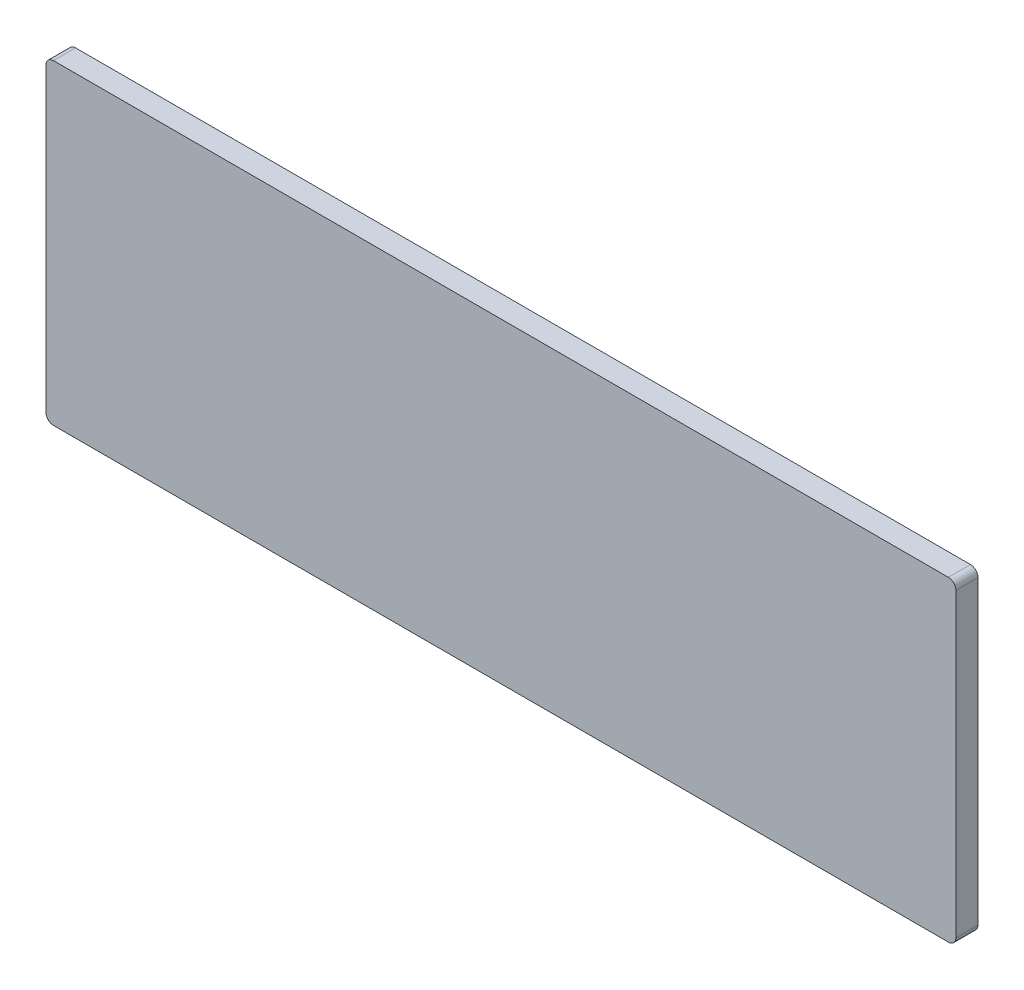
from build123d import *

# Parameters (mm, degrees)
SKETCH1_W           = 1828.8
SKETCH1_H           = 635
BOSS_EXTRUDE1_DEPTH = 44.45
FILLET1_R           = 15


with BuildPart() as part:
    # Sketch1 → Boss-Extrude1 (new body)
    with BuildSketch(Plane.XY):
        Rectangle(SKETCH1_W, SKETCH1_H)
    extrude(amount=-BOSS_EXTRUDE1_DEPTH)

    # Fillet1
    fillet1_edges = [part.edges().sort_by_distance(p)[0] for p in [
        (-914.4, 317.5, -22.225),
        (914.4, 317.5, -22.225),
        (914.4, -317.5, -22.225),
        (-914.4, -317.5, -22.225),
    ]]
    fillet(fillet1_edges, radius=FILLET1_R)


solid = part.part
